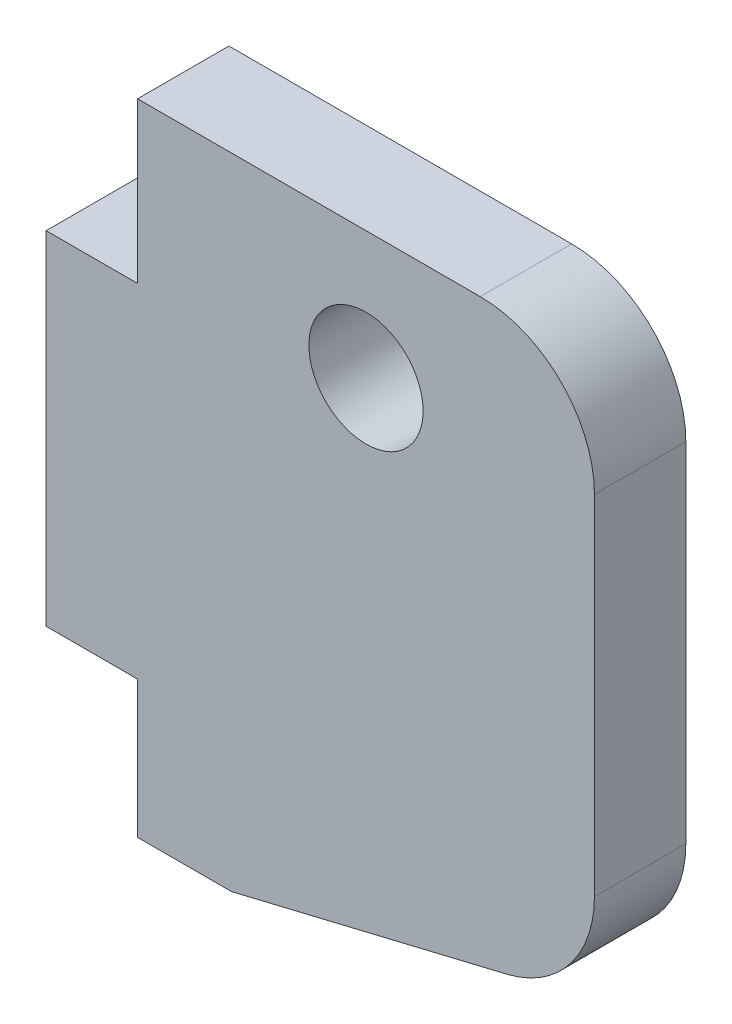
from build123d import *

# Parameters (mm, degrees)
SKETCH_1_R      = 2.5
EXTRUDE_1_DEPTH = 4
FILLET_1_R      = 5


with BuildPart() as part:
    # ｽｹｯﾁ1 → ﾎﾞｽ - 押し出し1 (new body)
    with BuildSketch(Plane.XY):
        Polygon((0, 15), (0, 0), (4, 0), (4, -6), (8.110763801, -6), (24, -2.18322685), (24, 22), (4, 22), (4, 15), align=None)
        with Locations((14, 16.41)):
            Circle(SKETCH_1_R, mode=Mode.SUBTRACT)
    extrude(amount=EXTRUDE_1_DEPTH)

    # ﾌｨﾚｯﾄ1
    fillet_1_edges = [part.edges().sort_by_distance(p)[0] for p in [
        (24, 22, 2),
        (24, -2.18322685, 2),
    ]]
    fillet(fillet_1_edges, radius=FILLET_1_R)


solid = part.part
